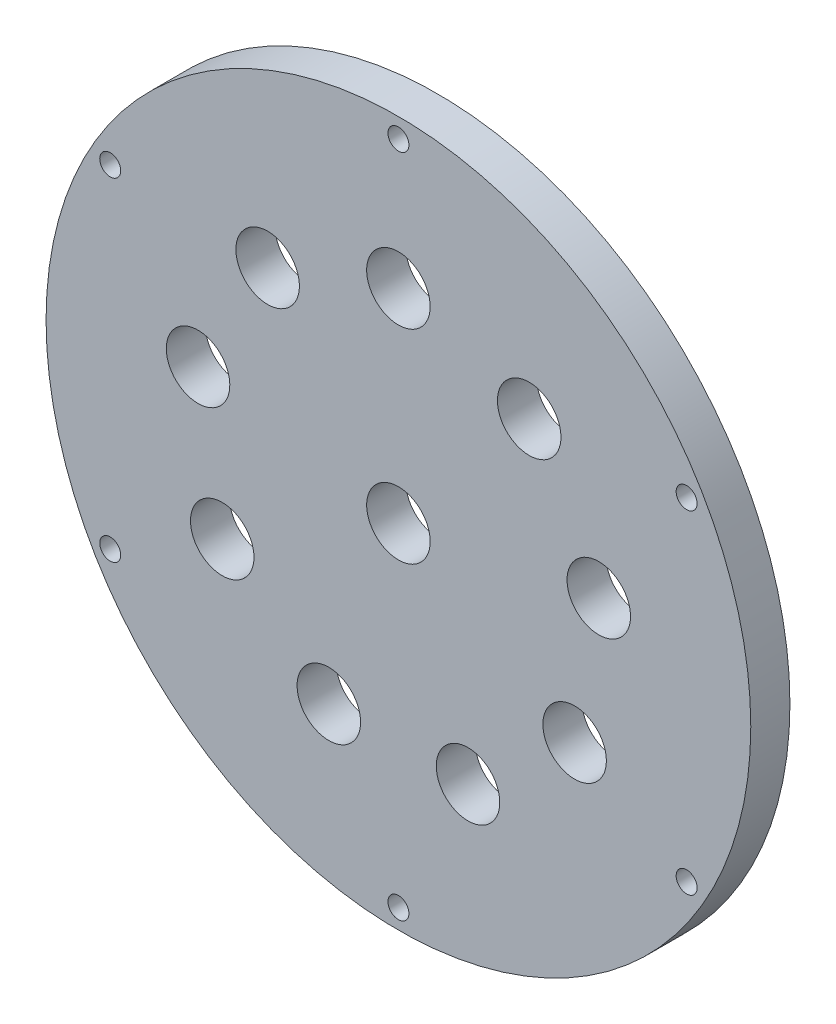
from build123d import *

# Parameters (mm, degrees)
SKETCH2_R           = 57.15
BOSS_EXTRUDE1_DEPTH = 6.35
SKETCH3_R           = 5.15
CUT_EXTRUDE1_DEPTH  = 7.35
CIRPATTERN1_COUNT   = 9
SKETCH6_R           = 1.7
CUT_EXTRUDE4_DEPTH  = 7.35
CIRPATTERN3_COUNT   = 6
SKETCH7_R           = 5.15
CUT_EXTRUDE5_DEPTH  = 7.35


with BuildPart() as part:
    # Sketch2 → Boss-Extrude1 (new body)
    with BuildSketch(Plane.XY):
        Circle(SKETCH2_R)
    extrude(amount=BOSS_EXTRUDE1_DEPTH)

    # Sketch3 → Cut-Extrude1 (cut, through all)
    with BuildSketch(Plane.XY.offset(6.35)):
        with Locations((0, 33)):
            Circle(SKETCH3_R)
    cut_extrude1 = extrude(amount=-CUT_EXTRUDE1_DEPTH, mode=Mode.SUBTRACT)

    # CirPattern1: Cut-Extrude1 ×9 about axis
    cirpattern1_axis = Axis((0, 0, 0), (0, 0, 1))
    for i in range(1, CIRPATTERN1_COUNT):
        add(cut_extrude1.rotate(cirpattern1_axis, i * 360 / CIRPATTERN1_COUNT), mode=Mode.SUBTRACT)

    # Sketch6 → Cut-Extrude4 (cut, through all)
    with BuildSketch(Plane.XY.offset(6.35)):
        with Locations((0, 53.975)):
            Circle(SKETCH6_R)
    cut_extrude4 = extrude(amount=-CUT_EXTRUDE4_DEPTH, mode=Mode.SUBTRACT)

    # CirPattern3: Cut-Extrude4 ×6 about axis
    cirpattern3_axis = Axis((0, 0, 0), (0, 0, 1))
    for i in range(1, CIRPATTERN3_COUNT):
        add(cut_extrude4.rotate(cirpattern3_axis, i * 360 / CIRPATTERN3_COUNT), mode=Mode.SUBTRACT)

    # Sketch7 → Cut-Extrude5 (cut, through all)
    with BuildSketch(Plane.XY.offset(6.35)):
        Circle(SKETCH7_R)
    extrude(amount=-CUT_EXTRUDE5_DEPTH, mode=Mode.SUBTRACT)


solid = part.part
